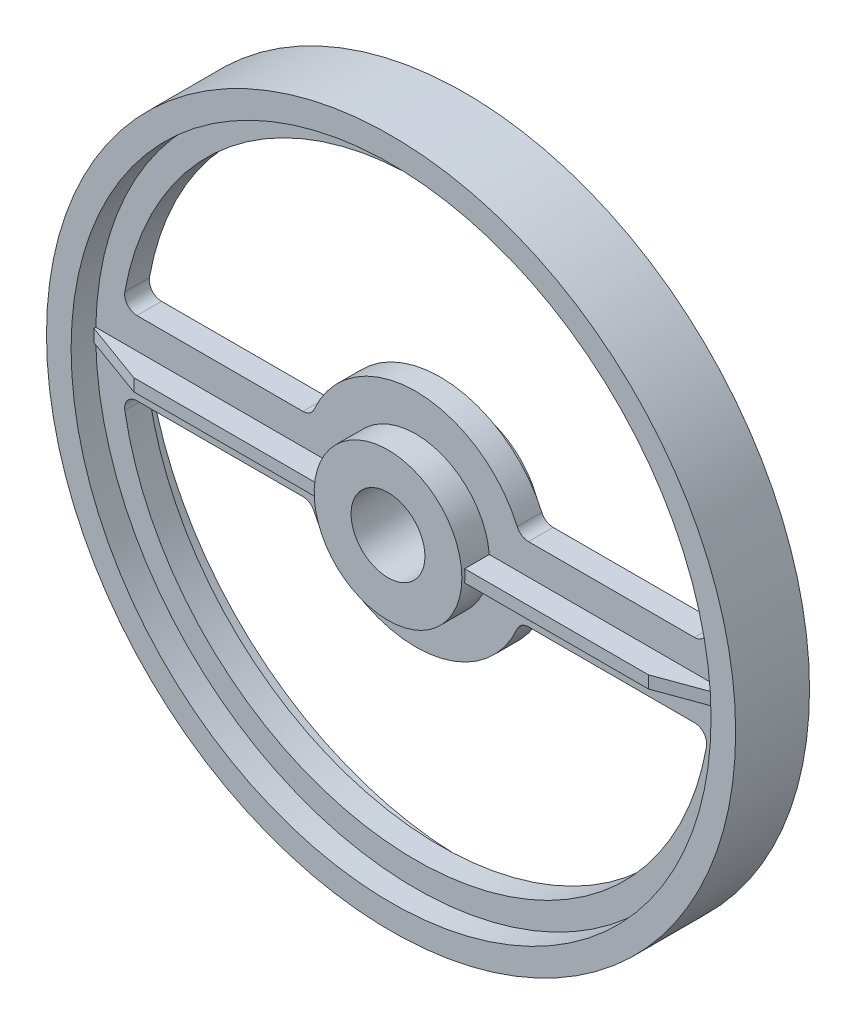
from build123d import *

# Parameters (mm, degrees)
SKETCH1_R                = 38.1
CENTERHUB_DEPTH          = 20.6375
RIB_DEPTH                = 3.175
LIGHTENING_HOLE_DEPTH    = 21.6375
FILLET1_R                = 6.35
CIRPATTERN1_COUNT        = 2
FILLET1_OF_CIRPATTERN1_R = 6.35
SKETCH5_R                = 19.05
THRU_HOLE_DEPTH          = 21.6375
THRU_HOLE_DEPTH_BACK     = 21.6375


with BuildPart() as part:
    # Sketch1 → CenterHub (new body, symmetric)
    with BuildSketch(Plane.XY):
        Circle(SKETCH1_R)
    extrude(amount=CENTERHUB_DEPTH, both=True)

    # Sketch2 → Rim and Web (revolve)
    with BuildSketch(Plane(origin=(0, 0, 0), x_dir=(0, 0, -1), z_dir=(1, 0, 0))):
        Polygon((-6.35, 0), (6.35, 0), (6.35, 165.1), (19.05, 165.1), (19.05, 177.8), (-19.05, 177.8), (-19.05, 165.1), (-6.35, 165.1), align=None)
    revolve(axis=Axis((0, 0, 0), (0, 0, -1)))

    # Sketch3 → Rib (add, symmetric)
    with BuildSketch(Plane(origin=(0, 0, 0), x_dir=(1, 0, 0), z_dir=(0, 1, 0))):
        Polygon((0, -19.05), (132.747036773, -19.05), (167.64, -6.35), (167.64, 6.35), (132.747036773, 19.05), (0, 19.05), align=None)
    rib = extrude(amount=RIB_DEPTH, both=True)

    # Sketch4 → Lightening hole (cut, symmetric)
    with BuildSketch(Plane.XY):
        with BuildLine():
            Line((-151.204687427, -19.05), (-53.881536726, -19.05))
            ThreePointArc((-53.881536726, -19.05), (0, -57.15), (53.881536726, -19.05))
            Line((53.881536726, -19.05), (151.204687427, -19.05))
            ThreePointArc((151.204687427, -19.05), (0, -152.4), (-151.204687427, -19.05))
        make_face()
    lightening_hole = extrude(amount=LIGHTENING_HOLE_DEPTH, both=True, mode=Mode.SUBTRACT)

    # Fillet1
    fillet1_edges = [part.edges().sort_by_distance(p)[0] for p in [
        (151.204687427, -19.05, 0),
        (-151.204687427, -19.05, 0),
        (-53.881536726, -19.05, 0),
        (53.881536726, -19.05, 0),
    ]]
    fillet(fillet1_edges, radius=FILLET1_R)

    # CirPattern1: Rib, Lightening hole ×2 about axis
    cirpattern1_axis = Axis((0, 0, 0), (0, 0, 1))
    for i in range(1, CIRPATTERN1_COUNT):
        add(rib.rotate(cirpattern1_axis, i * 360 / CIRPATTERN1_COUNT))
        add(lightening_hole.rotate(cirpattern1_axis, i * 360 / CIRPATTERN1_COUNT), mode=Mode.SUBTRACT)

    # Fillet1 of CirPattern1
    fillet1_of_cirpattern1_edges = [part.edges().sort_by_distance(p)[0] for p in [
        (-151.204687427, 19.05, 0),
        (151.204687427, 19.05, 0),
        (53.881536726, 19.05, 0),
        (-53.881536726, 19.05, 0),
    ]]
    fillet(fillet1_of_cirpattern1_edges, radius=FILLET1_OF_CIRPATTERN1_R)

    # Sketch5 → Thru hole (cut, two sides)
    with BuildSketch(Plane.XY) as thru_hole_sk:
        Circle(SKETCH5_R)
    extrude(amount=THRU_HOLE_DEPTH, mode=Mode.SUBTRACT)
    extrude(thru_hole_sk.sketch, amount=-THRU_HOLE_DEPTH_BACK, mode=Mode.SUBTRACT)


solid = part.part
